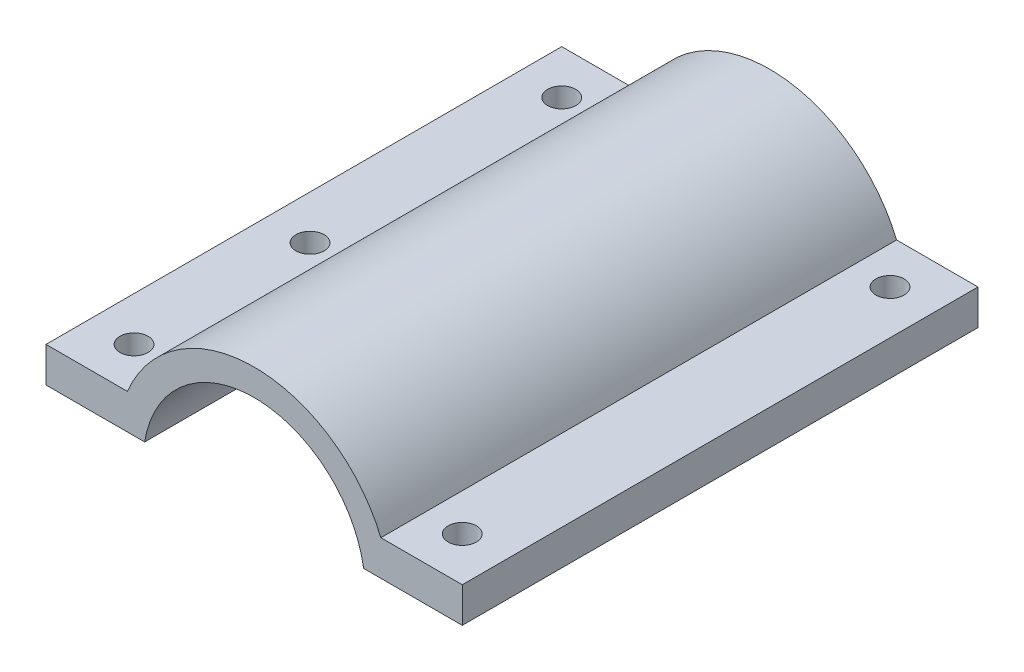
from build123d import *

# Parameters (mm, degrees)
BOSS_EXTRUDE1_DEPTH = 58.6
SKETCH2_R           = 1.6
CUT_EXTRUDE1_DEPTH  = 58.6


with BuildPart() as part:
    # Sketch1 → Boss-Extrude1 (new body)
    with BuildSketch(Plane.XY):
        with BuildLine():
            Line((-23.65, 6), (-14.4, 6))
            ThreePointArc((-14.4, 6), (0, 15.6), (14.4, 6))
            Line((14.4, 6), (23.65, 6))
            Line((23.65, 6), (23.65, 2))
            Line((23.65, 2), (12.440257232, 2))
            ThreePointArc((12.440257232, 2), (0, 12.6), (-12.440257232, 2))
            Line((-12.440257232, 2), (-23.65, 2))
            Line((-23.65, 2), (-23.65, 6))
        make_face()
    extrude(amount=BOSS_EXTRUDE1_DEPTH)

    # Sketch2 → Cut-Extrude1 (cut)
    with BuildSketch(Plane(origin=(0, 6, 0), x_dir=(1, 0, 0), z_dir=(0, 1, 0))):
        with Locations((18.65, -5)):
            Circle(SKETCH2_R)
        with Locations((18.65, -53.6)):
            Circle(SKETCH2_R)
        with Locations((-18.65, -53.6)):
            Circle(SKETCH2_R)
        with Locations((-18.65, -5)):
            Circle(SKETCH2_R)
        with Locations((-18.65, -33.6)):
            Circle(SKETCH2_R)
    extrude(amount=-CUT_EXTRUDE1_DEPTH, mode=Mode.SUBTRACT)


solid = part.part
